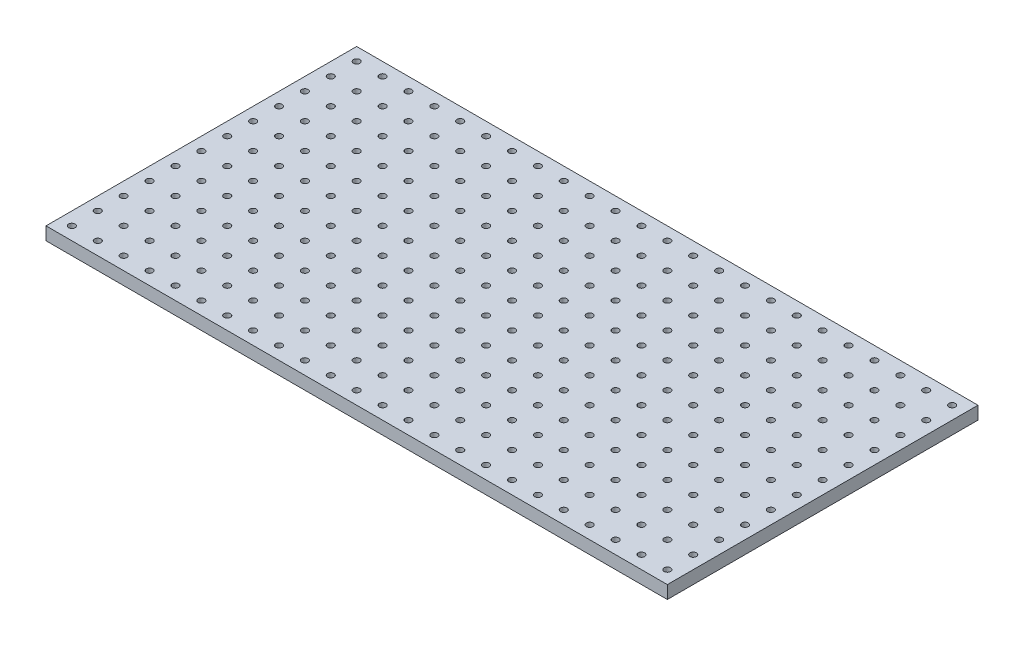
from build123d import *

# Parameters (mm, degrees)
SKETCH1_W           = 609.6
SKETCH1_H           = 304.8
BOSS_EXTRUDE1_DEPTH = 12.7
SKETCH2_R           = 3.175
CUT_EXTRUDE1_DEPTH  = 13.7


with BuildPart() as part:
    # Sketch1 → Boss-Extrude1 (new body)
    with BuildSketch(Plane(origin=(0, 0, 0), x_dir=(1, 0, 0), z_dir=(0, 1, 0))):
        with Locations((304.8, 152.4)):
            Rectangle(SKETCH1_W, SKETCH1_H)
    extrude(amount=BOSS_EXTRUDE1_DEPTH)

    # Sketch2 → Cut-Extrude1 (cut, through all)
    with BuildSketch(Plane(origin=(0, 12.7, 0), x_dir=(1, 0, 0), z_dir=(0, 1, 0))):
        with Locations((12.7, 12.7)):
            Circle(SKETCH2_R)
        with Locations((38.1, 12.7)):
            Circle(SKETCH2_R)
        with Locations((63.5, 12.7)):
            Circle(SKETCH2_R)
        with Locations((88.9, 12.7)):
            Circle(SKETCH2_R)
        with Locations((114.3, 12.7)):
            Circle(SKETCH2_R)
        with Locations((139.7, 12.7)):
            Circle(SKETCH2_R)
        with Locations((165.1, 12.7)):
            Circle(SKETCH2_R)
        with Locations((190.5, 12.7)):
            Circle(SKETCH2_R)
        with Locations((215.9, 12.7)):
            Circle(SKETCH2_R)
        with Locations((241.3, 12.7)):
            Circle(SKETCH2_R)
        with Locations((266.7, 12.7)):
            Circle(SKETCH2_R)
        with Locations((292.1, 12.7)):
            Circle(SKETCH2_R)
        with Locations((317.5, 12.7)):
            Circle(SKETCH2_R)
        with Locations((342.9, 12.7)):
            Circle(SKETCH2_R)
        with Locations((368.3, 12.7)):
            Circle(SKETCH2_R)
        with Locations((393.7, 12.7)):
            Circle(SKETCH2_R)
        with Locations((419.1, 12.7)):
            Circle(SKETCH2_R)
        with Locations((444.5, 12.7)):
            Circle(SKETCH2_R)
        with Locations((469.9, 12.7)):
            Circle(SKETCH2_R)
        with Locations((495.3, 12.7)):
            Circle(SKETCH2_R)
        with Locations((520.7, 12.7)):
            Circle(SKETCH2_R)
        with Locations((546.1, 12.7)):
            Circle(SKETCH2_R)
        with Locations((571.5, 12.7)):
            Circle(SKETCH2_R)
        with Locations((596.9, 12.7)):
            Circle(SKETCH2_R)
        with Locations((38.1, 38.1)):
            Circle(SKETCH2_R)
        with Locations((63.5, 38.1)):
            Circle(SKETCH2_R)
        with Locations((88.9, 38.1)):
            Circle(SKETCH2_R)
        with Locations((114.3, 38.1)):
            Circle(SKETCH2_R)
        with Locations((139.7, 38.1)):
            Circle(SKETCH2_R)
        with Locations((165.1, 38.1)):
            Circle(SKETCH2_R)
        with Locations((190.5, 38.1)):
            Circle(SKETCH2_R)
        with Locations((215.9, 38.1)):
            Circle(SKETCH2_R)
        with Locations((241.3, 38.1)):
            Circle(SKETCH2_R)
        with Locations((266.7, 38.1)):
            Circle(SKETCH2_R)
        with Locations((292.1, 38.1)):
            Circle(SKETCH2_R)
        with Locations((317.5, 38.1)):
            Circle(SKETCH2_R)
        with Locations((342.9, 38.1)):
            Circle(SKETCH2_R)
        with Locations((368.3, 38.1)):
            Circle(SKETCH2_R)
        with Locations((393.7, 38.1)):
            Circle(SKETCH2_R)
        with Locations((419.1, 38.1)):
            Circle(SKETCH2_R)
        with Locations((444.5, 38.1)):
            Circle(SKETCH2_R)
        with Locations((469.9, 38.1)):
            Circle(SKETCH2_R)
        with Locations((495.3, 38.1)):
            Circle(SKETCH2_R)
        with Locations((520.7, 38.1)):
            Circle(SKETCH2_R)
        with Locations((546.1, 38.1)):
            Circle(SKETCH2_R)
        with Locations((571.5, 38.1)):
            Circle(SKETCH2_R)
        with Locations((596.9, 38.1)):
            Circle(SKETCH2_R)
        with Locations((38.1, 63.5)):
            Circle(SKETCH2_R)
        with Locations((63.5, 63.5)):
            Circle(SKETCH2_R)
        with Locations((88.9, 63.5)):
            Circle(SKETCH2_R)
        with Locations((114.3, 63.5)):
            Circle(SKETCH2_R)
        with Locations((139.7, 63.5)):
            Circle(SKETCH2_R)
        with Locations((165.1, 63.5)):
            Circle(SKETCH2_R)
        with Locations((190.5, 63.5)):
            Circle(SKETCH2_R)
        with Locations((215.9, 63.5)):
            Circle(SKETCH2_R)
        with Locations((241.3, 63.5)):
            Circle(SKETCH2_R)
        with Locations((266.7, 63.5)):
            Circle(SKETCH2_R)
        with Locations((292.1, 63.5)):
            Circle(SKETCH2_R)
        with Locations((317.5, 63.5)):
            Circle(SKETCH2_R)
        with Locations((342.9, 63.5)):
            Circle(SKETCH2_R)
        with Locations((368.3, 63.5)):
            Circle(SKETCH2_R)
        with Locations((393.7, 63.5)):
            Circle(SKETCH2_R)
        with Locations((419.1, 63.5)):
            Circle(SKETCH2_R)
        with Locations((444.5, 63.5)):
            Circle(SKETCH2_R)
        with Locations((469.9, 63.5)):
            Circle(SKETCH2_R)
        with Locations((495.3, 63.5)):
            Circle(SKETCH2_R)
        with Locations((520.7, 63.5)):
            Circle(SKETCH2_R)
        with Locations((546.1, 63.5)):
            Circle(SKETCH2_R)
        with Locations((571.5, 63.5)):
            Circle(SKETCH2_R)
        with Locations((596.9, 63.5)):
            Circle(SKETCH2_R)
        with Locations((38.1, 88.9)):
            Circle(SKETCH2_R)
        with Locations((63.5, 88.9)):
            Circle(SKETCH2_R)
        with Locations((88.9, 88.9)):
            Circle(SKETCH2_R)
        with Locations((114.3, 88.9)):
            Circle(SKETCH2_R)
        with Locations((139.7, 88.9)):
            Circle(SKETCH2_R)
        with Locations((165.1, 88.9)):
            Circle(SKETCH2_R)
        with Locations((190.5, 88.9)):
            Circle(SKETCH2_R)
        with Locations((215.9, 88.9)):
            Circle(SKETCH2_R)
        with Locations((241.3, 88.9)):
            Circle(SKETCH2_R)
        with Locations((266.7, 88.9)):
            Circle(SKETCH2_R)
        with Locations((292.1, 88.9)):
            Circle(SKETCH2_R)
        with Locations((317.5, 88.9)):
            Circle(SKETCH2_R)
        with Locations((342.9, 88.9)):
            Circle(SKETCH2_R)
        with Locations((368.3, 88.9)):
            Circle(SKETCH2_R)
        with Locations((393.7, 88.9)):
            Circle(SKETCH2_R)
        with Locations((419.1, 88.9)):
            Circle(SKETCH2_R)
        with Locations((444.5, 88.9)):
            Circle(SKETCH2_R)
        with Locations((469.9, 88.9)):
            Circle(SKETCH2_R)
        with Locations((495.3, 88.9)):
            Circle(SKETCH2_R)
        with Locations((520.7, 88.9)):
            Circle(SKETCH2_R)
        with Locations((546.1, 88.9)):
            Circle(SKETCH2_R)
        with Locations((571.5, 88.9)):
            Circle(SKETCH2_R)
        with Locations((596.9, 88.9)):
            Circle(SKETCH2_R)
        with Locations((38.1, 114.3)):
            Circle(SKETCH2_R)
        with Locations((63.5, 114.3)):
            Circle(SKETCH2_R)
        with Locations((88.9, 114.3)):
            Circle(SKETCH2_R)
        with Locations((114.3, 114.3)):
            Circle(SKETCH2_R)
        with Locations((139.7, 114.3)):
            Circle(SKETCH2_R)
        with Locations((165.1, 114.3)):
            Circle(SKETCH2_R)
        with Locations((190.5, 114.3)):
            Circle(SKETCH2_R)
        with Locations((215.9, 114.3)):
            Circle(SKETCH2_R)
        with Locations((241.3, 114.3)):
            Circle(SKETCH2_R)
        with Locations((266.7, 114.3)):
            Circle(SKETCH2_R)
        with Locations((292.1, 114.3)):
            Circle(SKETCH2_R)
        with Locations((317.5, 114.3)):
            Circle(SKETCH2_R)
        with Locations((342.9, 114.3)):
            Circle(SKETCH2_R)
        with Locations((368.3, 114.3)):
            Circle(SKETCH2_R)
        with Locations((393.7, 114.3)):
            Circle(SKETCH2_R)
        with Locations((419.1, 114.3)):
            Circle(SKETCH2_R)
        with Locations((444.5, 114.3)):
            Circle(SKETCH2_R)
        with Locations((469.9, 114.3)):
            Circle(SKETCH2_R)
        with Locations((495.3, 114.3)):
            Circle(SKETCH2_R)
        with Locations((520.7, 114.3)):
            Circle(SKETCH2_R)
        with Locations((546.1, 114.3)):
            Circle(SKETCH2_R)
        with Locations((571.5, 114.3)):
            Circle(SKETCH2_R)
        with Locations((596.9, 114.3)):
            Circle(SKETCH2_R)
        with Locations((38.1, 139.7)):
            Circle(SKETCH2_R)
        with Locations((63.5, 139.7)):
            Circle(SKETCH2_R)
        with Locations((88.9, 139.7)):
            Circle(SKETCH2_R)
        with Locations((114.3, 139.7)):
            Circle(SKETCH2_R)
        with Locations((139.7, 139.7)):
            Circle(SKETCH2_R)
        with Locations((165.1, 139.7)):
            Circle(SKETCH2_R)
        with Locations((190.5, 139.7)):
            Circle(SKETCH2_R)
        with Locations((215.9, 139.7)):
            Circle(SKETCH2_R)
        with Locations((241.3, 139.7)):
            Circle(SKETCH2_R)
        with Locations((266.7, 139.7)):
            Circle(SKETCH2_R)
        with Locations((292.1, 139.7)):
            Circle(SKETCH2_R)
        with Locations((317.5, 139.7)):
            Circle(SKETCH2_R)
        with Locations((342.9, 139.7)):
            Circle(SKETCH2_R)
        with Locations((368.3, 139.7)):
            Circle(SKETCH2_R)
        with Locations((393.7, 139.7)):
            Circle(SKETCH2_R)
        with Locations((419.1, 139.7)):
            Circle(SKETCH2_R)
        with Locations((444.5, 139.7)):
            Circle(SKETCH2_R)
        with Locations((469.9, 139.7)):
            Circle(SKETCH2_R)
        with Locations((495.3, 139.7)):
            Circle(SKETCH2_R)
        with Locations((520.7, 139.7)):
            Circle(SKETCH2_R)
        with Locations((546.1, 139.7)):
            Circle(SKETCH2_R)
        with Locations((571.5, 139.7)):
            Circle(SKETCH2_R)
        with Locations((596.9, 139.7)):
            Circle(SKETCH2_R)
        with Locations((38.1, 165.1)):
            Circle(SKETCH2_R)
        with Locations((63.5, 165.1)):
            Circle(SKETCH2_R)
        with Locations((88.9, 165.1)):
            Circle(SKETCH2_R)
        with Locations((114.3, 165.1)):
            Circle(SKETCH2_R)
        with Locations((139.7, 165.1)):
            Circle(SKETCH2_R)
        with Locations((165.1, 165.1)):
            Circle(SKETCH2_R)
        with Locations((190.5, 165.1)):
            Circle(SKETCH2_R)
        with Locations((215.9, 165.1)):
            Circle(SKETCH2_R)
        with Locations((241.3, 165.1)):
            Circle(SKETCH2_R)
        with Locations((266.7, 165.1)):
            Circle(SKETCH2_R)
        with Locations((292.1, 165.1)):
            Circle(SKETCH2_R)
        with Locations((317.5, 165.1)):
            Circle(SKETCH2_R)
        with Locations((342.9, 165.1)):
            Circle(SKETCH2_R)
        with Locations((368.3, 165.1)):
            Circle(SKETCH2_R)
        with Locations((393.7, 165.1)):
            Circle(SKETCH2_R)
        with Locations((419.1, 165.1)):
            Circle(SKETCH2_R)
        with Locations((444.5, 165.1)):
            Circle(SKETCH2_R)
        with Locations((469.9, 165.1)):
            Circle(SKETCH2_R)
        with Locations((495.3, 165.1)):
            Circle(SKETCH2_R)
        with Locations((520.7, 165.1)):
            Circle(SKETCH2_R)
        with Locations((546.1, 165.1)):
            Circle(SKETCH2_R)
        with Locations((571.5, 165.1)):
            Circle(SKETCH2_R)
        with Locations((596.9, 165.1)):
            Circle(SKETCH2_R)
        with Locations((38.1, 190.5)):
            Circle(SKETCH2_R)
        with Locations((63.5, 190.5)):
            Circle(SKETCH2_R)
        with Locations((88.9, 190.5)):
            Circle(SKETCH2_R)
        with Locations((114.3, 190.5)):
            Circle(SKETCH2_R)
        with Locations((139.7, 190.5)):
            Circle(SKETCH2_R)
        with Locations((165.1, 190.5)):
            Circle(SKETCH2_R)
        with Locations((190.5, 190.5)):
            Circle(SKETCH2_R)
        with Locations((215.9, 190.5)):
            Circle(SKETCH2_R)
        with Locations((241.3, 190.5)):
            Circle(SKETCH2_R)
        with Locations((266.7, 190.5)):
            Circle(SKETCH2_R)
        with Locations((292.1, 190.5)):
            Circle(SKETCH2_R)
        with Locations((317.5, 190.5)):
            Circle(SKETCH2_R)
        with Locations((342.9, 190.5)):
            Circle(SKETCH2_R)
        with Locations((368.3, 190.5)):
            Circle(SKETCH2_R)
        with Locations((393.7, 190.5)):
            Circle(SKETCH2_R)
        with Locations((419.1, 190.5)):
            Circle(SKETCH2_R)
        with Locations((444.5, 190.5)):
            Circle(SKETCH2_R)
        with Locations((469.9, 190.5)):
            Circle(SKETCH2_R)
        with Locations((495.3, 190.5)):
            Circle(SKETCH2_R)
        with Locations((520.7, 190.5)):
            Circle(SKETCH2_R)
        with Locations((546.1, 190.5)):
            Circle(SKETCH2_R)
        with Locations((571.5, 190.5)):
            Circle(SKETCH2_R)
        with Locations((596.9, 190.5)):
            Circle(SKETCH2_R)
        with Locations((38.1, 215.9)):
            Circle(SKETCH2_R)
        with Locations((63.5, 215.9)):
            Circle(SKETCH2_R)
        with Locations((88.9, 215.9)):
            Circle(SKETCH2_R)
        with Locations((114.3, 215.9)):
            Circle(SKETCH2_R)
        with Locations((139.7, 215.9)):
            Circle(SKETCH2_R)
        with Locations((165.1, 215.9)):
            Circle(SKETCH2_R)
        with Locations((190.5, 215.9)):
            Circle(SKETCH2_R)
        with Locations((215.9, 215.9)):
            Circle(SKETCH2_R)
        with Locations((241.3, 215.9)):
            Circle(SKETCH2_R)
        with Locations((266.7, 215.9)):
            Circle(SKETCH2_R)
        with Locations((292.1, 215.9)):
            Circle(SKETCH2_R)
        with Locations((317.5, 215.9)):
            Circle(SKETCH2_R)
        with Locations((342.9, 215.9)):
            Circle(SKETCH2_R)
        with Locations((368.3, 215.9)):
            Circle(SKETCH2_R)
        with Locations((393.7, 215.9)):
            Circle(SKETCH2_R)
        with Locations((419.1, 215.9)):
            Circle(SKETCH2_R)
        with Locations((444.5, 215.9)):
            Circle(SKETCH2_R)
        with Locations((469.9, 215.9)):
            Circle(SKETCH2_R)
        with Locations((495.3, 215.9)):
            Circle(SKETCH2_R)
        with Locations((520.7, 215.9)):
            Circle(SKETCH2_R)
        with Locations((546.1, 215.9)):
            Circle(SKETCH2_R)
        with Locations((571.5, 215.9)):
            Circle(SKETCH2_R)
        with Locations((596.9, 215.9)):
            Circle(SKETCH2_R)
        with Locations((38.1, 241.3)):
            Circle(SKETCH2_R)
        with Locations((63.5, 241.3)):
            Circle(SKETCH2_R)
        with Locations((88.9, 241.3)):
            Circle(SKETCH2_R)
        with Locations((114.3, 241.3)):
            Circle(SKETCH2_R)
        with Locations((139.7, 241.3)):
            Circle(SKETCH2_R)
        with Locations((165.1, 241.3)):
            Circle(SKETCH2_R)
        with Locations((190.5, 241.3)):
            Circle(SKETCH2_R)
        with Locations((215.9, 241.3)):
            Circle(SKETCH2_R)
        with Locations((241.3, 241.3)):
            Circle(SKETCH2_R)
        with Locations((266.7, 241.3)):
            Circle(SKETCH2_R)
        with Locations((292.1, 241.3)):
            Circle(SKETCH2_R)
        with Locations((317.5, 241.3)):
            Circle(SKETCH2_R)
        with Locations((342.9, 241.3)):
            Circle(SKETCH2_R)
        with Locations((368.3, 241.3)):
            Circle(SKETCH2_R)
        with Locations((393.7, 241.3)):
            Circle(SKETCH2_R)
        with Locations((419.1, 241.3)):
            Circle(SKETCH2_R)
        with Locations((444.5, 241.3)):
            Circle(SKETCH2_R)
        with Locations((469.9, 241.3)):
            Circle(SKETCH2_R)
        with Locations((495.3, 241.3)):
            Circle(SKETCH2_R)
        with Locations((520.7, 241.3)):
            Circle(SKETCH2_R)
        with Locations((546.1, 241.3)):
            Circle(SKETCH2_R)
        with Locations((571.5, 241.3)):
            Circle(SKETCH2_R)
        with Locations((596.9, 241.3)):
            Circle(SKETCH2_R)
        with Locations((38.1, 266.7)):
            Circle(SKETCH2_R)
        with Locations((63.5, 266.7)):
            Circle(SKETCH2_R)
        with Locations((88.9, 266.7)):
            Circle(SKETCH2_R)
        with Locations((114.3, 266.7)):
            Circle(SKETCH2_R)
        with Locations((139.7, 266.7)):
            Circle(SKETCH2_R)
        with Locations((165.1, 266.7)):
            Circle(SKETCH2_R)
        with Locations((190.5, 266.7)):
            Circle(SKETCH2_R)
        with Locations((215.9, 266.7)):
            Circle(SKETCH2_R)
        with Locations((241.3, 266.7)):
            Circle(SKETCH2_R)
        with Locations((266.7, 266.7)):
            Circle(SKETCH2_R)
        with Locations((292.1, 266.7)):
            Circle(SKETCH2_R)
        with Locations((317.5, 266.7)):
            Circle(SKETCH2_R)
        with Locations((342.9, 266.7)):
            Circle(SKETCH2_R)
        with Locations((368.3, 266.7)):
            Circle(SKETCH2_R)
        with Locations((393.7, 266.7)):
            Circle(SKETCH2_R)
        with Locations((419.1, 266.7)):
            Circle(SKETCH2_R)
        with Locations((444.5, 266.7)):
            Circle(SKETCH2_R)
        with Locations((469.9, 266.7)):
            Circle(SKETCH2_R)
        with Locations((495.3, 266.7)):
            Circle(SKETCH2_R)
        with Locations((520.7, 266.7)):
            Circle(SKETCH2_R)
        with Locations((546.1, 266.7)):
            Circle(SKETCH2_R)
        with Locations((571.5, 266.7)):
            Circle(SKETCH2_R)
        with Locations((596.9, 266.7)):
            Circle(SKETCH2_R)
        with Locations((38.1, 292.1)):
            Circle(SKETCH2_R)
        with Locations((63.5, 292.1)):
            Circle(SKETCH2_R)
        with Locations((88.9, 292.1)):
            Circle(SKETCH2_R)
        with Locations((114.3, 292.1)):
            Circle(SKETCH2_R)
        with Locations((139.7, 292.1)):
            Circle(SKETCH2_R)
        with Locations((165.1, 292.1)):
            Circle(SKETCH2_R)
        with Locations((190.5, 292.1)):
            Circle(SKETCH2_R)
        with Locations((215.9, 292.1)):
            Circle(SKETCH2_R)
        with Locations((241.3, 292.1)):
            Circle(SKETCH2_R)
        with Locations((266.7, 292.1)):
            Circle(SKETCH2_R)
        with Locations((292.1, 292.1)):
            Circle(SKETCH2_R)
        with Locations((317.5, 292.1)):
            Circle(SKETCH2_R)
        with Locations((342.9, 292.1)):
            Circle(SKETCH2_R)
        with Locations((368.3, 292.1)):
            Circle(SKETCH2_R)
        with Locations((393.7, 292.1)):
            Circle(SKETCH2_R)
        with Locations((419.1, 292.1)):
            Circle(SKETCH2_R)
        with Locations((444.5, 292.1)):
            Circle(SKETCH2_R)
        with Locations((469.9, 292.1)):
            Circle(SKETCH2_R)
        with Locations((495.3, 292.1)):
            Circle(SKETCH2_R)
        with Locations((520.7, 292.1)):
            Circle(SKETCH2_R)
        with Locations((546.1, 292.1)):
            Circle(SKETCH2_R)
        with Locations((571.5, 292.1)):
            Circle(SKETCH2_R)
        with Locations((596.9, 292.1)):
            Circle(SKETCH2_R)
        with Locations((12.7, 38.1)):
            Circle(SKETCH2_R)
        with Locations((12.7, 63.5)):
            Circle(SKETCH2_R)
        with Locations((12.7, 88.9)):
            Circle(SKETCH2_R)
        with Locations((12.7, 114.3)):
            Circle(SKETCH2_R)
        with Locations((12.7, 139.7)):
            Circle(SKETCH2_R)
        with Locations((12.7, 165.1)):
            Circle(SKETCH2_R)
        with Locations((12.7, 190.5)):
            Circle(SKETCH2_R)
        with Locations((12.7, 215.9)):
            Circle(SKETCH2_R)
        with Locations((12.7, 241.3)):
            Circle(SKETCH2_R)
        with Locations((12.7, 266.7)):
            Circle(SKETCH2_R)
        with Locations((12.7, 292.1)):
            Circle(SKETCH2_R)
    extrude(amount=-CUT_EXTRUDE1_DEPTH, mode=Mode.SUBTRACT)


solid = part.part
